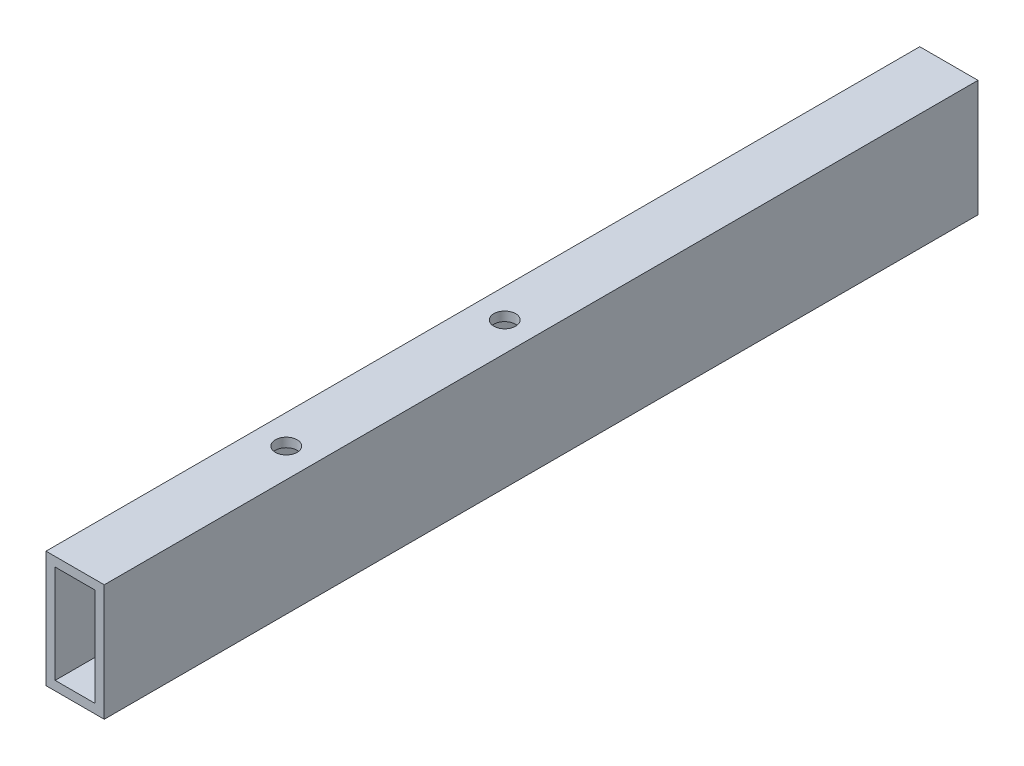
from build123d import *

# Parameters (mm, degrees)
SKETCH1_W             = 40
SKETCH1_H             = 80
SKETCH1_W_2           = 27.4
SKETCH1_H_2           = 67.4
M12_CLEARANCE_HOLE1_D = 15


with BuildPart() as part:
    # Sweep1: sweep along a curve in space
    with BuildLine() as sweep1_path:
        add(Edge.make_bspline(
            [(0, 0, -300), (0, 0, 300)],
            knots=[0, 0, 1, 1], degree=1))
    # Sketch1 → Sweep1 (sweep)
    with BuildSketch(Plane.XY):
        Rectangle(SKETCH1_W, SKETCH1_H)
        Rectangle(SKETCH1_W_2, SKETCH1_H_2, mode=Mode.SUBTRACT)
    sweep(path=sweep1_path.line)

    # M12 Clearance Hole1 (through all)
    with Locations(Plane(origin=(0, 40, 0), x_dir=(1, 0, 0), z_dir=(0, 1, 0))):
        with Locations((0, -155), (0, -5)):
            Hole(M12_CLEARANCE_HOLE1_D / 2)


solid = part.part
